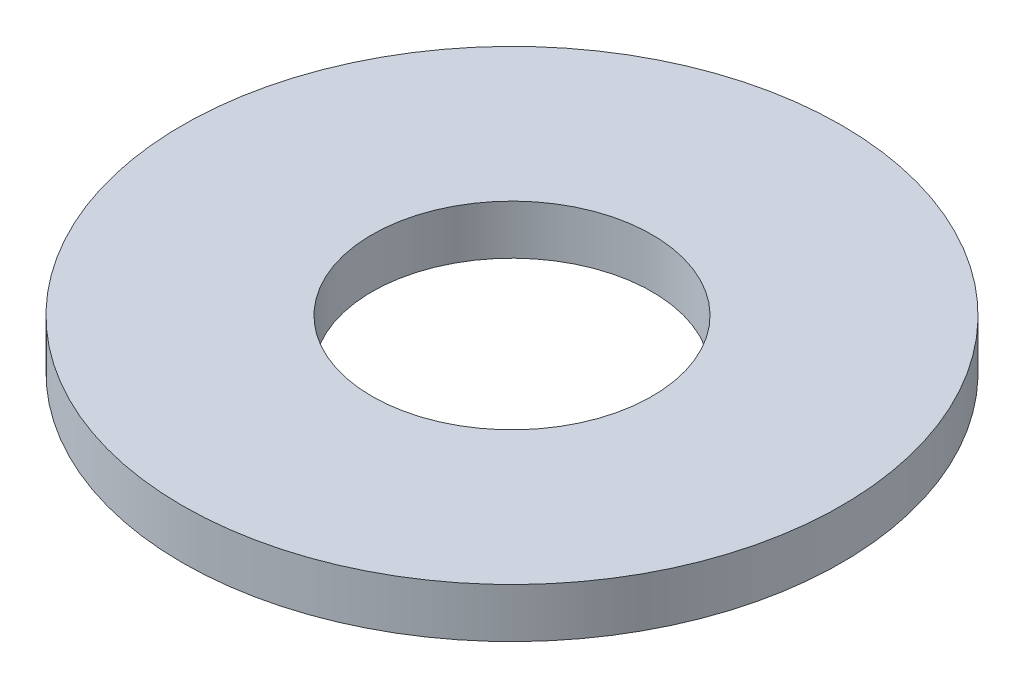
from build123d import *

# Parameters (mm, degrees)
SKETCH1_R           = 40
SKETCH1_R_2         = 17
BOSS_EXTRUDE1_DEPTH = 6


with BuildPart() as part:
    # Sketch1 → Boss-Extrude1 (new body)
    with BuildSketch(Plane(origin=(0, 0, 0), x_dir=(1, 0, 0), z_dir=(0, 1, 0))):
        Circle(SKETCH1_R)
        Circle(SKETCH1_R_2, mode=Mode.SUBTRACT)
    extrude(amount=BOSS_EXTRUDE1_DEPTH)


solid = part.part
